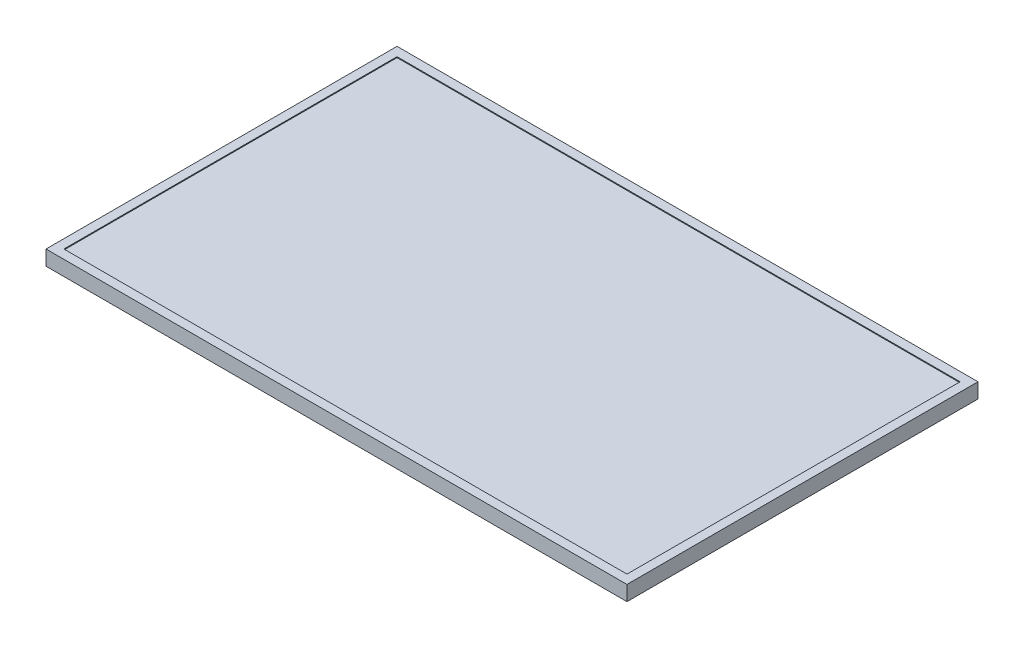
from build123d import *

# Parameters (mm, degrees)
SKETCH1_W           = 1649.984
SKETCH1_H           = 996.95
BOSS_EXTRUDE1_DEPTH = 39.878
SKETCH2_W           = 1649.984
SKETCH2_H           = 996.95
SKETCH2_W_2         = 1599.184
SKETCH2_H_2         = 946.15
BOSS_EXTRUDE2_DEPTH = 2.54


with BuildPart() as part:
    # Sketch1 → Boss-Extrude1 (new body)
    with BuildSketch(Plane(origin=(0, 0, 0), x_dir=(1, 0, 0), z_dir=(0, 1, 0))):
        with Locations((824.992, 498.475)):
            Rectangle(SKETCH1_W, SKETCH1_H)
    extrude(amount=BOSS_EXTRUDE1_DEPTH)

    # Sketch2 → Boss-Extrude2 (add)
    with BuildSketch(Plane(origin=(0, 39.878, 0), x_dir=(1, 0, 0), z_dir=(0, 1, 0))):
        with Locations((824.992, 498.475)):
            Rectangle(SKETCH2_W, SKETCH2_H)
        with Locations((824.992, 498.475)):
            Rectangle(SKETCH2_W_2, SKETCH2_H_2, mode=Mode.SUBTRACT)
    extrude(amount=BOSS_EXTRUDE2_DEPTH)


solid = part.part
